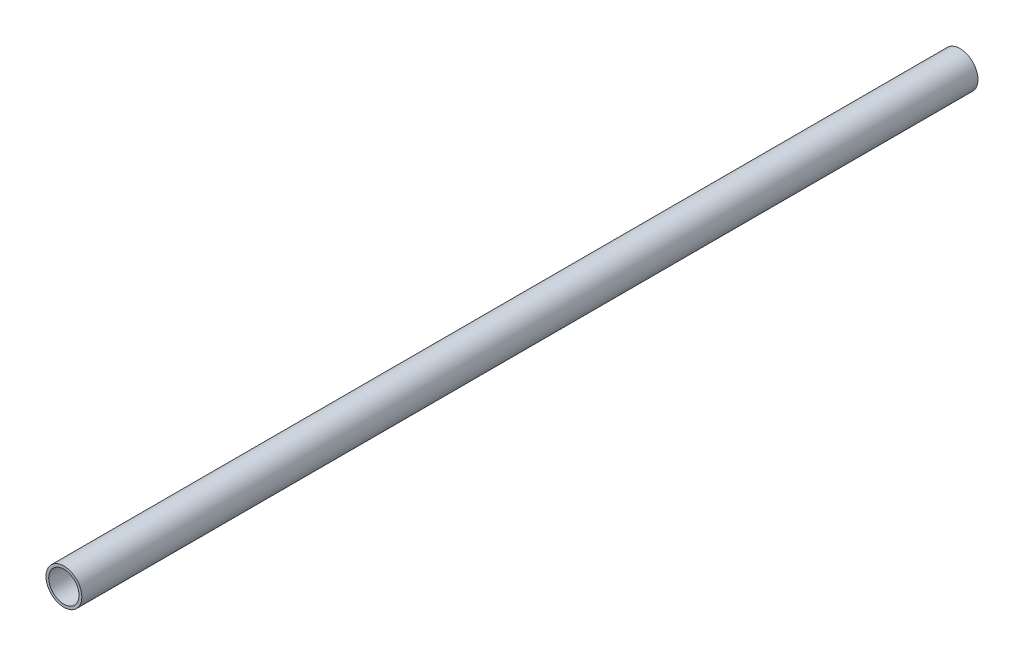
from build123d import *

# Parameters (mm, degrees)
CROQUIS1_R              = 30
SALIENTE_EXTRUIR1_DEPTH = 1500
CROQUIS2_R              = 25.4
CORTAR_EXTRUIR1_DEPTH   = 1501


with BuildPart() as part:
    # Croquis1 → Saliente-Extruir1 (new body)
    with BuildSketch(Plane.XY):
        Circle(CROQUIS1_R)
    extrude(amount=SALIENTE_EXTRUIR1_DEPTH)

    # Croquis2 → Cortar-Extruir1 (cut, through all)
    with BuildSketch(Plane.XY.offset(1500)):
        Circle(CROQUIS2_R)
    extrude(amount=-CORTAR_EXTRUIR1_DEPTH, mode=Mode.SUBTRACT)


solid = part.part
